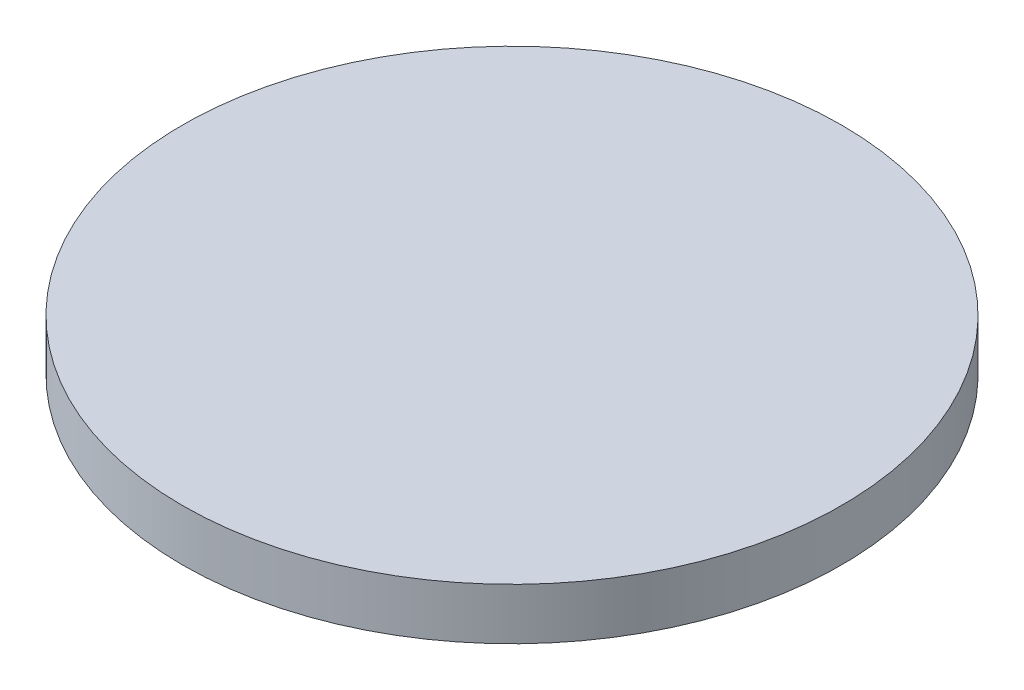
from build123d import *

# Parameters (mm, degrees)
SKETCH1_R           = 20.32
BOSS_EXTRUDE1_DEPTH = 3.175


with BuildPart() as part:
    # Sketch1 → Boss-Extrude1 (new body)
    with BuildSketch(Plane(origin=(0, 0, 0), x_dir=(1, 0, 0), z_dir=(0, 1, 0))):
        Circle(SKETCH1_R)
    extrude(amount=BOSS_EXTRUDE1_DEPTH)


solid = part.part
